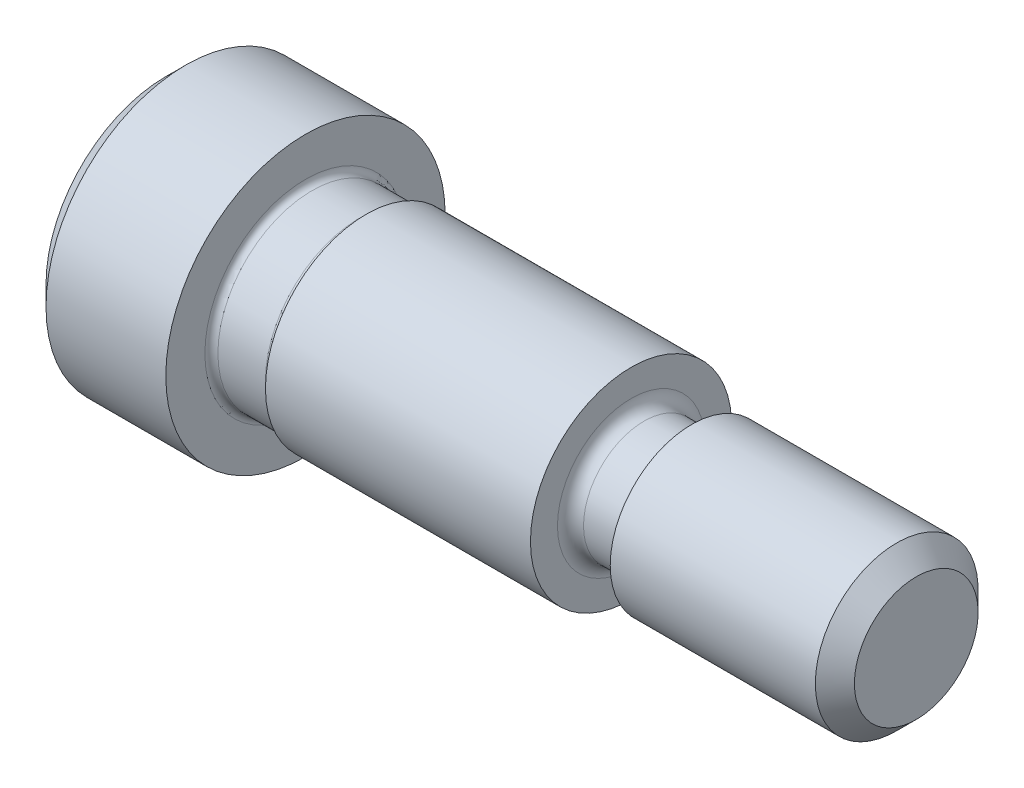
from build123d import *


with BuildPart() as part:
    # Sketch1 → Revolve1 (revolve)
    with BuildSketch(Plane.XY):
        with BuildLine():
            Line((26.023627587, 46.178938329), (30.697227587, 46.178938329))
            Line((30.697227587, 46.178938329), (30.697227587, 44.908938329))
            Line((30.697227587, 44.908938329), (30.697227587, 44.654938329))
            ThreePointArc((30.697227587, 44.654938329), (30.771622465, 44.475333206), (30.951227587, 44.400938329))
            Line((30.951227587, 44.400938329), (31.205227587, 44.400938329))
            Line((31.205227587, 44.400938329), (32.805427587, 44.400938329))
            ThreePointArc((32.805427587, 44.400938329), (32.98503271, 44.475333206), (33.059427587, 44.654938329))
            Line((33.059427587, 44.654938329), (43.397227587, 44.654938329))
            Line((43.397227587, 44.654938329), (43.397227587, 43.600838329))
            ThreePointArc((43.397227587, 43.600838329), (43.546017342, 43.241628084), (43.905227587, 43.092838329))
            Line((43.905227587, 43.092838329), (45.505427587, 43.092838329))
            ThreePointArc((45.505427587, 43.092838329), (45.68503271, 43.167233206), (45.759427587, 43.346838329))
            Line((45.759427587, 43.346838329), (45.759427587, 43.905638329))
            Line((45.759427587, 43.905638329), (53.760427587, 43.905638329))
            Line((53.760427587, 43.905638329), (54.522427587, 43.143638329))
            Line((54.522427587, 43.143638329), (54.522427587, 40.730638329))
            Line((54.522427587, 40.730638329), (25.261627587, 40.730638329))
            Line((25.261627587, 40.730638329), (25.261627587, 45.416938329))
            Line((25.261627587, 45.416938329), (26.023627587, 46.178938329))
        make_face()
    revolve(axis=Axis((25.261627587, 40.730638329, 0), (1, 0, 0)))


solid = part.part
